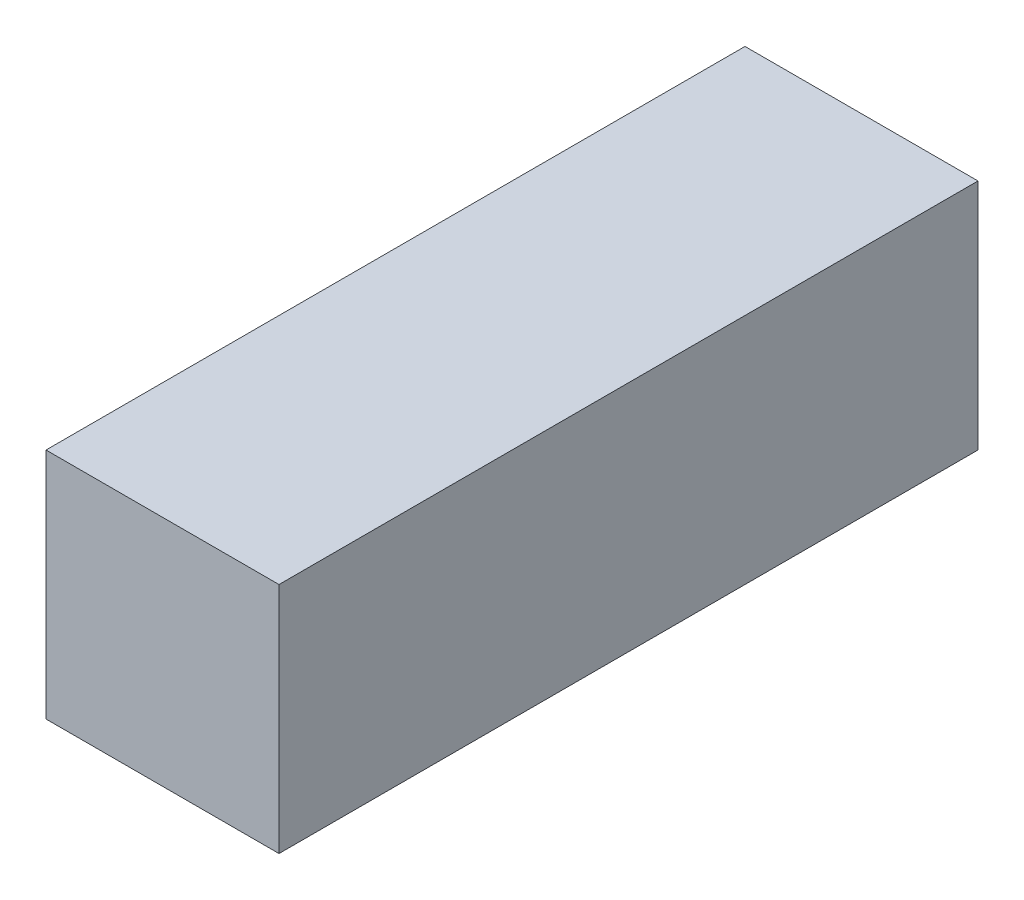
from build123d import *

# Parameters (mm, degrees)
SKETCH1_W           = 200
SKETCH1_H           = 600
BOSS_EXTRUDE1_DEPTH = 200


with BuildPart() as part:
    # Sketch1 → Boss-Extrude1 (new body)
    with BuildSketch(Plane(origin=(0, 0, 0), x_dir=(1, 0, 0), z_dir=(0, 1, 0))):
        with Locations((42.495842889, 259.038134661)):
            Rectangle(SKETCH1_W, SKETCH1_H)
    extrude(amount=BOSS_EXTRUDE1_DEPTH)


solid = part.part
